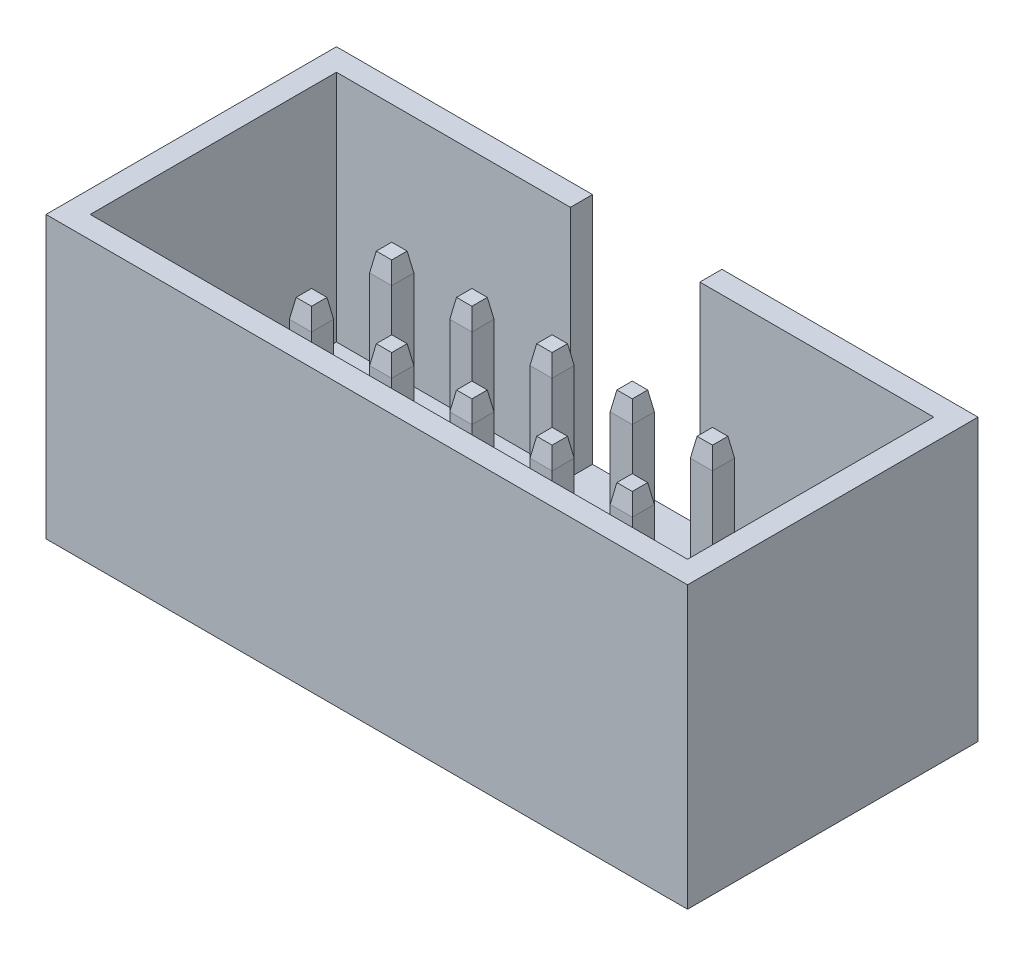
from build123d import *

# Parameters (mm, degrees)
SZKIC1_W                         = 20.32
SZKIC1_H                         = 9.2
DODANIE_WYCI_GNI_CIE1_DEPTH      = 8.9
SZKIC2_W                         = 18.92
SZKIC2_H                         = 7.8
WYTNIJ_WYCI_GNI_CIE1_DEPTH       = 7.4
SZKIC3_W                         = 4.1
SZKIC3_H                         = 0.7
WYTNIJ_WYCI_GNI_CIE2_DEPTH       = 7.4
SZKIC4_W                         = 0.7
SZKIC4_H                         = 0.7
DODANIE_WYCI_GNI_CIE2_DEPTH      = 6
DODANIE_WYCI_GNI_CIE2_DEPTH_BACK = 4
SFAZOWANIE1_SIZE                 = 0.6
SFAZOWANIE1_SIZE2                = 0.105796188
SFAZOWANIE1_PART_2_SIZE          = 0.6
SFAZOWANIE1_PART_2_SIZE2         = 0.105796188
SFAZOWANIE1_PART_3_SIZE          = 0.6
SFAZOWANIE1_PART_3_SIZE2         = 0.105796188
SFAZOWANIE1_PART_4_SIZE          = 0.6
SFAZOWANIE1_PART_4_SIZE2         = 0.105796188
SFAZOWANIE1_PART_5_SIZE          = 0.6
SFAZOWANIE1_PART_5_SIZE2         = 0.105796188
SFAZOWANIE1_PART_6_SIZE          = 0.6
SFAZOWANIE1_PART_6_SIZE2         = 0.105796188
SFAZOWANIE1_PART_7_SIZE          = 0.6
SFAZOWANIE1_PART_7_SIZE2         = 0.105796188
SFAZOWANIE1_PART_8_SIZE          = 0.6
SFAZOWANIE1_PART_8_SIZE2         = 0.105796188
SFAZOWANIE1_PART_9_SIZE          = 0.6
SFAZOWANIE1_PART_9_SIZE2         = 0.105796188
SFAZOWANIE1_PART_10_SIZE         = 0.6
SFAZOWANIE1_PART_10_SIZE2        = 0.105796188
SFAZOWANIE1_PART_11_SIZE         = 0.6
SFAZOWANIE1_PART_11_SIZE2        = 0.105796188
SFAZOWANIE1_PART_12_SIZE         = 0.6
SFAZOWANIE1_PART_12_SIZE2        = 0.105796188
SFAZOWANIE1_PART_13_SIZE         = 0.6
SFAZOWANIE1_PART_13_SIZE2        = 0.105796188
SFAZOWANIE1_PART_14_SIZE         = 0.6
SFAZOWANIE1_PART_14_SIZE2        = 0.105796188
SFAZOWANIE1_PART_15_SIZE         = 0.6
SFAZOWANIE1_PART_15_SIZE2        = 0.105796188
SFAZOWANIE1_PART_16_SIZE         = 0.6
SFAZOWANIE1_PART_16_SIZE2        = 0.105796188
SFAZOWANIE1_PART_17_SIZE         = 0.6
SFAZOWANIE1_PART_17_SIZE2        = 0.105796188
SFAZOWANIE1_PART_18_SIZE         = 0.6
SFAZOWANIE1_PART_18_SIZE2        = 0.105796188
SFAZOWANIE1_PART_19_SIZE         = 0.6
SFAZOWANIE1_PART_19_SIZE2        = 0.105796188
SFAZOWANIE1_PART_20_SIZE         = 0.6
SFAZOWANIE1_PART_20_SIZE2        = 0.105796188
SFAZOWANIE1_PART_21_SIZE         = 0.6
SFAZOWANIE1_PART_21_SIZE2        = 0.105796188
SFAZOWANIE1_PART_22_SIZE         = 0.6
SFAZOWANIE1_PART_22_SIZE2        = 0.105796188
SFAZOWANIE1_PART_23_SIZE         = 0.6
SFAZOWANIE1_PART_23_SIZE2        = 0.105796188
SFAZOWANIE1_PART_24_SIZE         = 0.6
SFAZOWANIE1_PART_24_SIZE2        = 0.105796188
SFAZOWANIE1_PART_25_SIZE         = 0.6
SFAZOWANIE1_PART_25_SIZE2        = 0.105796188
SFAZOWANIE1_PART_26_SIZE         = 0.6
SFAZOWANIE1_PART_26_SIZE2        = 0.105796188
SFAZOWANIE1_PART_27_SIZE         = 0.6
SFAZOWANIE1_PART_27_SIZE2        = 0.105796188
SFAZOWANIE1_PART_28_SIZE         = 0.6
SFAZOWANIE1_PART_28_SIZE2        = 0.105796188
SFAZOWANIE1_PART_29_SIZE         = 0.6
SFAZOWANIE1_PART_29_SIZE2        = 0.105796188
SFAZOWANIE1_PART_30_SIZE         = 0.6
SFAZOWANIE1_PART_30_SIZE2        = 0.105796188
SFAZOWANIE1_PART_31_SIZE         = 0.6
SFAZOWANIE1_PART_31_SIZE2        = 0.105796188
SFAZOWANIE1_PART_32_SIZE         = 0.6
SFAZOWANIE1_PART_32_SIZE2        = 0.105796188
SFAZOWANIE1_PART_33_SIZE         = 0.6
SFAZOWANIE1_PART_33_SIZE2        = 0.105796188
SFAZOWANIE1_PART_34_SIZE         = 0.6
SFAZOWANIE1_PART_34_SIZE2        = 0.105796188
SFAZOWANIE1_PART_35_SIZE         = 0.6
SFAZOWANIE1_PART_35_SIZE2        = 0.105796188
SFAZOWANIE1_PART_36_SIZE         = 0.6
SFAZOWANIE1_PART_36_SIZE2        = 0.105796188
SFAZOWANIE1_PART_37_SIZE         = 0.6
SFAZOWANIE1_PART_37_SIZE2        = 0.105796188
SFAZOWANIE1_PART_38_SIZE         = 0.6
SFAZOWANIE1_PART_38_SIZE2        = 0.105796188
SFAZOWANIE1_PART_39_SIZE         = 0.6
SFAZOWANIE1_PART_39_SIZE2        = 0.105796188
SFAZOWANIE1_PART_40_SIZE         = 0.6
SFAZOWANIE1_PART_40_SIZE2        = 0.105796188
SFAZOWANIE2_SIZE                 = 0.6
SFAZOWANIE2_SIZE2                = 0.105796188
SFAZOWANIE2_PART_2_SIZE          = 0.6
SFAZOWANIE2_PART_2_SIZE2         = 0.105796188
SFAZOWANIE2_PART_3_SIZE          = 0.6
SFAZOWANIE2_PART_3_SIZE2         = 0.105796188
SFAZOWANIE2_PART_4_SIZE          = 0.6
SFAZOWANIE2_PART_4_SIZE2         = 0.105796188
SFAZOWANIE2_PART_5_SIZE          = 0.6
SFAZOWANIE2_PART_5_SIZE2         = 0.105796188
SFAZOWANIE2_PART_6_SIZE          = 0.6
SFAZOWANIE2_PART_6_SIZE2         = 0.105796188
SFAZOWANIE2_PART_7_SIZE          = 0.6
SFAZOWANIE2_PART_7_SIZE2         = 0.105796188
SFAZOWANIE2_PART_8_SIZE          = 0.6
SFAZOWANIE2_PART_8_SIZE2         = 0.105796188
SFAZOWANIE2_PART_9_SIZE          = 0.6
SFAZOWANIE2_PART_9_SIZE2         = 0.105796188
SFAZOWANIE2_PART_10_SIZE         = 0.6
SFAZOWANIE2_PART_10_SIZE2        = 0.105796188
SFAZOWANIE2_PART_11_SIZE         = 0.6
SFAZOWANIE2_PART_11_SIZE2        = 0.105796188
SFAZOWANIE2_PART_12_SIZE         = 0.6
SFAZOWANIE2_PART_12_SIZE2        = 0.105796188
SFAZOWANIE2_PART_13_SIZE         = 0.6
SFAZOWANIE2_PART_13_SIZE2        = 0.105796188
SFAZOWANIE2_PART_14_SIZE         = 0.6
SFAZOWANIE2_PART_14_SIZE2        = 0.105796188
SFAZOWANIE2_PART_15_SIZE         = 0.6
SFAZOWANIE2_PART_15_SIZE2        = 0.105796188
SFAZOWANIE2_PART_16_SIZE         = 0.6
SFAZOWANIE2_PART_16_SIZE2        = 0.105796188
SFAZOWANIE2_PART_17_SIZE         = 0.6
SFAZOWANIE2_PART_17_SIZE2        = 0.105796188
SFAZOWANIE2_PART_18_SIZE         = 0.6
SFAZOWANIE2_PART_18_SIZE2        = 0.105796188
SFAZOWANIE2_PART_19_SIZE         = 0.6
SFAZOWANIE2_PART_19_SIZE2        = 0.105796188
SFAZOWANIE2_PART_20_SIZE         = 0.6
SFAZOWANIE2_PART_20_SIZE2        = 0.105796188
SFAZOWANIE2_PART_21_SIZE         = 0.6
SFAZOWANIE2_PART_21_SIZE2        = 0.105796188
SFAZOWANIE2_PART_22_SIZE         = 0.6
SFAZOWANIE2_PART_22_SIZE2        = 0.105796188
SFAZOWANIE2_PART_23_SIZE         = 0.6
SFAZOWANIE2_PART_23_SIZE2        = 0.105796188
SFAZOWANIE2_PART_24_SIZE         = 0.6
SFAZOWANIE2_PART_24_SIZE2        = 0.105796188
SFAZOWANIE2_PART_25_SIZE         = 0.6
SFAZOWANIE2_PART_25_SIZE2        = 0.105796188
SFAZOWANIE2_PART_26_SIZE         = 0.6
SFAZOWANIE2_PART_26_SIZE2        = 0.105796188
SFAZOWANIE2_PART_27_SIZE         = 0.6
SFAZOWANIE2_PART_27_SIZE2        = 0.105796188
SFAZOWANIE2_PART_28_SIZE         = 0.6
SFAZOWANIE2_PART_28_SIZE2        = 0.105796188
SFAZOWANIE2_PART_29_SIZE         = 0.6
SFAZOWANIE2_PART_29_SIZE2        = 0.105796188
SFAZOWANIE2_PART_30_SIZE         = 0.6
SFAZOWANIE2_PART_30_SIZE2        = 0.105796188
SFAZOWANIE2_PART_31_SIZE         = 0.6
SFAZOWANIE2_PART_31_SIZE2        = 0.105796188
SFAZOWANIE2_PART_32_SIZE         = 0.6
SFAZOWANIE2_PART_32_SIZE2        = 0.105796188
SFAZOWANIE2_PART_33_SIZE         = 0.6
SFAZOWANIE2_PART_33_SIZE2        = 0.105796188
SFAZOWANIE2_PART_34_SIZE         = 0.6
SFAZOWANIE2_PART_34_SIZE2        = 0.105796188
SFAZOWANIE2_PART_35_SIZE         = 0.6
SFAZOWANIE2_PART_35_SIZE2        = 0.105796188
SFAZOWANIE2_PART_36_SIZE         = 0.6
SFAZOWANIE2_PART_36_SIZE2        = 0.105796188
SFAZOWANIE2_PART_37_SIZE         = 0.6
SFAZOWANIE2_PART_37_SIZE2        = 0.105796188
SFAZOWANIE2_PART_38_SIZE         = 0.6
SFAZOWANIE2_PART_38_SIZE2        = 0.105796188
SFAZOWANIE2_PART_39_SIZE         = 0.6
SFAZOWANIE2_PART_39_SIZE2        = 0.105796188
SFAZOWANIE2_PART_40_SIZE         = 0.6
SFAZOWANIE2_PART_40_SIZE2        = 0.105796188


with BuildPart() as part:
    # Szkic1 → Dodanie-wyciągnięcie1 (new body)
    with BuildSketch(Plane(origin=(0, 0, 0), x_dir=(1, 0, 0), z_dir=(0, 1, 0))):
        with Locations((10.16, 4.6)):
            Rectangle(SZKIC1_W, SZKIC1_H)
    extrude(amount=DODANIE_WYCI_GNI_CIE1_DEPTH)

    # Szkic2 → Wytnij-wyciągnięcie1 (cut)
    with BuildSketch(Plane(origin=(0, 8.9, 0), x_dir=(1, 0, 0), z_dir=(0, 1, 0))):
        with Locations((10.16, 4.6)):
            Rectangle(SZKIC2_W, SZKIC2_H)
    extrude(amount=-WYTNIJ_WYCI_GNI_CIE1_DEPTH, mode=Mode.SUBTRACT)

    # Szkic3 → Wytnij-wyciągnięcie2 (cut)
    with BuildSketch(Plane(origin=(0, 8.9, 0), x_dir=(1, 0, 0), z_dir=(0, 1, 0))):
        with Locations((10.16, 8.85)):
            Rectangle(SZKIC3_W, SZKIC3_H)
    extrude(amount=-WYTNIJ_WYCI_GNI_CIE2_DEPTH, mode=Mode.SUBTRACT)

    # Szkic4 → Dodanie-wyciągnięcie2 (add, two sides)
    with BuildSketch(Plane(origin=(0, 1.5, 0), x_dir=(1, 0, 0), z_dir=(0, 1, 0))) as dodanie_wyci_gni_cie2_sk:
        with Locations((5.08, 5.87)):
            Rectangle(SZKIC4_W, SZKIC4_H)
        with Locations((7.62, 5.87)):
            Rectangle(SZKIC4_W, SZKIC4_H)
        with Locations((10.16, 5.87)):
            Rectangle(SZKIC4_W, SZKIC4_H)
        with Locations((12.7, 5.87)):
            Rectangle(SZKIC4_W, SZKIC4_H)
        with Locations((15.24, 5.87)):
            Rectangle(SZKIC4_W, SZKIC4_H)
        with Locations((7.62, 3.33)):
            Rectangle(SZKIC4_W, SZKIC4_H)
        with Locations((10.16, 3.33)):
            Rectangle(SZKIC4_W, SZKIC4_H)
        with Locations((12.7, 3.33)):
            Rectangle(SZKIC4_W, SZKIC4_H)
        with Locations((15.24, 3.33)):
            Rectangle(SZKIC4_W, SZKIC4_H)
        with Locations((5.08, 3.33)):
            Rectangle(SZKIC4_W, SZKIC4_H)
    extrude(amount=DODANIE_WYCI_GNI_CIE2_DEPTH)
    extrude(dodanie_wyci_gni_cie2_sk.sketch, amount=-DODANIE_WYCI_GNI_CIE2_DEPTH_BACK)

    # Sfazowanie1
    sfazowanie1_edges = [part.edges().sort_by_distance(p)[0] for p in [
        (12.7, 7.5, -5.52),
    ]]
    sfazowanie1_side = [part.faces().sort_by_distance(p)[0] for p in [
        (12.7, 4.5, -5.52),
    ]]
    chamfer(sfazowanie1_edges, length=SFAZOWANIE1_SIZE, length2=SFAZOWANIE1_SIZE2, reference=sfazowanie1_side[0])

    # Sfazowanie1 part 2
    sfazowanie1_part_2_edges = [part.edges().sort_by_distance(p)[0] for p in [
        (13.05, 7.5, -5.87),
    ]]
    sfazowanie1_part_2_side = [part.faces().sort_by_distance(p)[0] for p in [
        (13.05, 4.5, -5.87),
    ]]
    chamfer(sfazowanie1_part_2_edges, length=SFAZOWANIE1_PART_2_SIZE, length2=SFAZOWANIE1_PART_2_SIZE2, reference=sfazowanie1_part_2_side[0])

    # Sfazowanie1 part 3
    sfazowanie1_part_3_edges = [part.edges().sort_by_distance(p)[0] for p in [
        (12.7, 7.5, -6.22),
    ]]
    sfazowanie1_part_3_side = [part.faces().sort_by_distance(p)[0] for p in [
        (12.7, 4.5, -6.22),
    ]]
    chamfer(sfazowanie1_part_3_edges, length=SFAZOWANIE1_PART_3_SIZE, length2=SFAZOWANIE1_PART_3_SIZE2, reference=sfazowanie1_part_3_side[0])

    # Sfazowanie1 part 4
    sfazowanie1_part_4_edges = [part.edges().sort_by_distance(p)[0] for p in [
        (12.35, 7.5, -5.87),
    ]]
    sfazowanie1_part_4_side = [part.faces().sort_by_distance(p)[0] for p in [
        (12.35, 4.5, -5.87),
    ]]
    chamfer(sfazowanie1_part_4_edges, length=SFAZOWANIE1_PART_4_SIZE, length2=SFAZOWANIE1_PART_4_SIZE2, reference=sfazowanie1_part_4_side[0])

    # Sfazowanie1 part 5
    sfazowanie1_part_5_edges = [part.edges().sort_by_distance(p)[0] for p in [
        (15.24, 7.5, -5.52),
    ]]
    sfazowanie1_part_5_side = [part.faces().sort_by_distance(p)[0] for p in [
        (15.24, 4.5, -5.52),
    ]]
    chamfer(sfazowanie1_part_5_edges, length=SFAZOWANIE1_PART_5_SIZE, length2=SFAZOWANIE1_PART_5_SIZE2, reference=sfazowanie1_part_5_side[0])

    # Sfazowanie1 part 6
    sfazowanie1_part_6_edges = [part.edges().sort_by_distance(p)[0] for p in [
        (15.59, 7.5, -5.87),
    ]]
    sfazowanie1_part_6_side = [part.faces().sort_by_distance(p)[0] for p in [
        (15.59, 4.5, -5.87),
    ]]
    chamfer(sfazowanie1_part_6_edges, length=SFAZOWANIE1_PART_6_SIZE, length2=SFAZOWANIE1_PART_6_SIZE2, reference=sfazowanie1_part_6_side[0])

    # Sfazowanie1 part 7
    sfazowanie1_part_7_edges = [part.edges().sort_by_distance(p)[0] for p in [
        (15.24, 7.5, -6.22),
    ]]
    sfazowanie1_part_7_side = [part.faces().sort_by_distance(p)[0] for p in [
        (15.24, 4.5, -6.22),
    ]]
    chamfer(sfazowanie1_part_7_edges, length=SFAZOWANIE1_PART_7_SIZE, length2=SFAZOWANIE1_PART_7_SIZE2, reference=sfazowanie1_part_7_side[0])

    # Sfazowanie1 part 8
    sfazowanie1_part_8_edges = [part.edges().sort_by_distance(p)[0] for p in [
        (14.89, 7.5, -5.87),
    ]]
    sfazowanie1_part_8_side = [part.faces().sort_by_distance(p)[0] for p in [
        (14.89, 4.5, -5.87),
    ]]
    chamfer(sfazowanie1_part_8_edges, length=SFAZOWANIE1_PART_8_SIZE, length2=SFAZOWANIE1_PART_8_SIZE2, reference=sfazowanie1_part_8_side[0])

    # Sfazowanie1 part 9
    sfazowanie1_part_9_edges = [part.edges().sort_by_distance(p)[0] for p in [
        (7.62, 7.5, -2.98),
    ]]
    sfazowanie1_part_9_side = [part.faces().sort_by_distance(p)[0] for p in [
        (7.62, 4.5, -2.98),
    ]]
    chamfer(sfazowanie1_part_9_edges, length=SFAZOWANIE1_PART_9_SIZE, length2=SFAZOWANIE1_PART_9_SIZE2, reference=sfazowanie1_part_9_side[0])

    # Sfazowanie1 part 10
    sfazowanie1_part_10_edges = [part.edges().sort_by_distance(p)[0] for p in [
        (7.97, 7.5, -3.33),
    ]]
    sfazowanie1_part_10_side = [part.faces().sort_by_distance(p)[0] for p in [
        (7.97, 4.5, -3.33),
    ]]
    chamfer(sfazowanie1_part_10_edges, length=SFAZOWANIE1_PART_10_SIZE, length2=SFAZOWANIE1_PART_10_SIZE2, reference=sfazowanie1_part_10_side[0])

    # Sfazowanie1 part 11
    sfazowanie1_part_11_edges = [part.edges().sort_by_distance(p)[0] for p in [
        (7.62, 7.5, -3.68),
    ]]
    sfazowanie1_part_11_side = [part.faces().sort_by_distance(p)[0] for p in [
        (7.62, 4.5, -3.68),
    ]]
    chamfer(sfazowanie1_part_11_edges, length=SFAZOWANIE1_PART_11_SIZE, length2=SFAZOWANIE1_PART_11_SIZE2, reference=sfazowanie1_part_11_side[0])

    # Sfazowanie1 part 12
    sfazowanie1_part_12_edges = [part.edges().sort_by_distance(p)[0] for p in [
        (7.27, 7.5, -3.33),
    ]]
    sfazowanie1_part_12_side = [part.faces().sort_by_distance(p)[0] for p in [
        (7.27, 4.5, -3.33),
    ]]
    chamfer(sfazowanie1_part_12_edges, length=SFAZOWANIE1_PART_12_SIZE, length2=SFAZOWANIE1_PART_12_SIZE2, reference=sfazowanie1_part_12_side[0])

    # Sfazowanie1 part 13
    sfazowanie1_part_13_edges = [part.edges().sort_by_distance(p)[0] for p in [
        (10.16, 7.5, -2.98),
    ]]
    sfazowanie1_part_13_side = [part.faces().sort_by_distance(p)[0] for p in [
        (10.16, 4.5, -2.98),
    ]]
    chamfer(sfazowanie1_part_13_edges, length=SFAZOWANIE1_PART_13_SIZE, length2=SFAZOWANIE1_PART_13_SIZE2, reference=sfazowanie1_part_13_side[0])

    # Sfazowanie1 part 14
    sfazowanie1_part_14_edges = [part.edges().sort_by_distance(p)[0] for p in [
        (10.51, 7.5, -3.33),
    ]]
    sfazowanie1_part_14_side = [part.faces().sort_by_distance(p)[0] for p in [
        (10.51, 4.5, -3.33),
    ]]
    chamfer(sfazowanie1_part_14_edges, length=SFAZOWANIE1_PART_14_SIZE, length2=SFAZOWANIE1_PART_14_SIZE2, reference=sfazowanie1_part_14_side[0])

    # Sfazowanie1 part 15
    sfazowanie1_part_15_edges = [part.edges().sort_by_distance(p)[0] for p in [
        (10.16, 7.5, -3.68),
    ]]
    sfazowanie1_part_15_side = [part.faces().sort_by_distance(p)[0] for p in [
        (10.16, 4.5, -3.68),
    ]]
    chamfer(sfazowanie1_part_15_edges, length=SFAZOWANIE1_PART_15_SIZE, length2=SFAZOWANIE1_PART_15_SIZE2, reference=sfazowanie1_part_15_side[0])

    # Sfazowanie1 part 16
    sfazowanie1_part_16_edges = [part.edges().sort_by_distance(p)[0] for p in [
        (9.81, 7.5, -3.33),
    ]]
    sfazowanie1_part_16_side = [part.faces().sort_by_distance(p)[0] for p in [
        (9.81, 4.5, -3.33),
    ]]
    chamfer(sfazowanie1_part_16_edges, length=SFAZOWANIE1_PART_16_SIZE, length2=SFAZOWANIE1_PART_16_SIZE2, reference=sfazowanie1_part_16_side[0])

    # Sfazowanie1 part 17
    sfazowanie1_part_17_edges = [part.edges().sort_by_distance(p)[0] for p in [
        (12.7, 7.5, -2.98),
    ]]
    sfazowanie1_part_17_side = [part.faces().sort_by_distance(p)[0] for p in [
        (12.7, 4.5, -2.98),
    ]]
    chamfer(sfazowanie1_part_17_edges, length=SFAZOWANIE1_PART_17_SIZE, length2=SFAZOWANIE1_PART_17_SIZE2, reference=sfazowanie1_part_17_side[0])

    # Sfazowanie1 part 18
    sfazowanie1_part_18_edges = [part.edges().sort_by_distance(p)[0] for p in [
        (13.05, 7.5, -3.33),
    ]]
    sfazowanie1_part_18_side = [part.faces().sort_by_distance(p)[0] for p in [
        (13.05, 4.5, -3.33),
    ]]
    chamfer(sfazowanie1_part_18_edges, length=SFAZOWANIE1_PART_18_SIZE, length2=SFAZOWANIE1_PART_18_SIZE2, reference=sfazowanie1_part_18_side[0])

    # Sfazowanie1 part 19
    sfazowanie1_part_19_edges = [part.edges().sort_by_distance(p)[0] for p in [
        (12.7, 7.5, -3.68),
    ]]
    sfazowanie1_part_19_side = [part.faces().sort_by_distance(p)[0] for p in [
        (12.7, 4.5, -3.68),
    ]]
    chamfer(sfazowanie1_part_19_edges, length=SFAZOWANIE1_PART_19_SIZE, length2=SFAZOWANIE1_PART_19_SIZE2, reference=sfazowanie1_part_19_side[0])

    # Sfazowanie1 part 20
    sfazowanie1_part_20_edges = [part.edges().sort_by_distance(p)[0] for p in [
        (12.35, 7.5, -3.33),
    ]]
    sfazowanie1_part_20_side = [part.faces().sort_by_distance(p)[0] for p in [
        (12.35, 4.5, -3.33),
    ]]
    chamfer(sfazowanie1_part_20_edges, length=SFAZOWANIE1_PART_20_SIZE, length2=SFAZOWANIE1_PART_20_SIZE2, reference=sfazowanie1_part_20_side[0])

    # Sfazowanie1 part 21
    sfazowanie1_part_21_edges = [part.edges().sort_by_distance(p)[0] for p in [
        (15.24, 7.5, -2.98),
    ]]
    sfazowanie1_part_21_side = [part.faces().sort_by_distance(p)[0] for p in [
        (15.24, 4.5, -2.98),
    ]]
    chamfer(sfazowanie1_part_21_edges, length=SFAZOWANIE1_PART_21_SIZE, length2=SFAZOWANIE1_PART_21_SIZE2, reference=sfazowanie1_part_21_side[0])

    # Sfazowanie1 part 22
    sfazowanie1_part_22_edges = [part.edges().sort_by_distance(p)[0] for p in [
        (15.59, 7.5, -3.33),
    ]]
    sfazowanie1_part_22_side = [part.faces().sort_by_distance(p)[0] for p in [
        (15.59, 4.5, -3.33),
    ]]
    chamfer(sfazowanie1_part_22_edges, length=SFAZOWANIE1_PART_22_SIZE, length2=SFAZOWANIE1_PART_22_SIZE2, reference=sfazowanie1_part_22_side[0])

    # Sfazowanie1 part 23
    sfazowanie1_part_23_edges = [part.edges().sort_by_distance(p)[0] for p in [
        (15.24, 7.5, -3.68),
    ]]
    sfazowanie1_part_23_side = [part.faces().sort_by_distance(p)[0] for p in [
        (15.24, 4.5, -3.68),
    ]]
    chamfer(sfazowanie1_part_23_edges, length=SFAZOWANIE1_PART_23_SIZE, length2=SFAZOWANIE1_PART_23_SIZE2, reference=sfazowanie1_part_23_side[0])

    # Sfazowanie1 part 24
    sfazowanie1_part_24_edges = [part.edges().sort_by_distance(p)[0] for p in [
        (14.89, 7.5, -3.33),
    ]]
    sfazowanie1_part_24_side = [part.faces().sort_by_distance(p)[0] for p in [
        (14.89, 4.5, -3.33),
    ]]
    chamfer(sfazowanie1_part_24_edges, length=SFAZOWANIE1_PART_24_SIZE, length2=SFAZOWANIE1_PART_24_SIZE2, reference=sfazowanie1_part_24_side[0])

    # Sfazowanie1 part 25
    sfazowanie1_part_25_edges = [part.edges().sort_by_distance(p)[0] for p in [
        (5.08, 7.5, -2.98),
    ]]
    sfazowanie1_part_25_side = [part.faces().sort_by_distance(p)[0] for p in [
        (5.08, 4.5, -2.98),
    ]]
    chamfer(sfazowanie1_part_25_edges, length=SFAZOWANIE1_PART_25_SIZE, length2=SFAZOWANIE1_PART_25_SIZE2, reference=sfazowanie1_part_25_side[0])

    # Sfazowanie1 part 26
    sfazowanie1_part_26_edges = [part.edges().sort_by_distance(p)[0] for p in [
        (5.43, 7.5, -3.33),
    ]]
    sfazowanie1_part_26_side = [part.faces().sort_by_distance(p)[0] for p in [
        (5.43, 4.5, -3.33),
    ]]
    chamfer(sfazowanie1_part_26_edges, length=SFAZOWANIE1_PART_26_SIZE, length2=SFAZOWANIE1_PART_26_SIZE2, reference=sfazowanie1_part_26_side[0])

    # Sfazowanie1 part 27
    sfazowanie1_part_27_edges = [part.edges().sort_by_distance(p)[0] for p in [
        (5.08, 7.5, -3.68),
    ]]
    sfazowanie1_part_27_side = [part.faces().sort_by_distance(p)[0] for p in [
        (5.08, 4.5, -3.68),
    ]]
    chamfer(sfazowanie1_part_27_edges, length=SFAZOWANIE1_PART_27_SIZE, length2=SFAZOWANIE1_PART_27_SIZE2, reference=sfazowanie1_part_27_side[0])

    # Sfazowanie1 part 28
    sfazowanie1_part_28_edges = [part.edges().sort_by_distance(p)[0] for p in [
        (4.73, 7.5, -3.33),
    ]]
    sfazowanie1_part_28_side = [part.faces().sort_by_distance(p)[0] for p in [
        (4.73, 4.5, -3.33),
    ]]
    chamfer(sfazowanie1_part_28_edges, length=SFAZOWANIE1_PART_28_SIZE, length2=SFAZOWANIE1_PART_28_SIZE2, reference=sfazowanie1_part_28_side[0])

    # Sfazowanie1 part 29
    sfazowanie1_part_29_edges = [part.edges().sort_by_distance(p)[0] for p in [
        (5.43, 7.5, -5.87),
    ]]
    sfazowanie1_part_29_side = [part.faces().sort_by_distance(p)[0] for p in [
        (5.43, 4.5, -5.87),
    ]]
    chamfer(sfazowanie1_part_29_edges, length=SFAZOWANIE1_PART_29_SIZE, length2=SFAZOWANIE1_PART_29_SIZE2, reference=sfazowanie1_part_29_side[0])

    # Sfazowanie1 part 30
    sfazowanie1_part_30_edges = [part.edges().sort_by_distance(p)[0] for p in [
        (5.08, 7.5, -6.22),
    ]]
    sfazowanie1_part_30_side = [part.faces().sort_by_distance(p)[0] for p in [
        (5.08, 4.5, -6.22),
    ]]
    chamfer(sfazowanie1_part_30_edges, length=SFAZOWANIE1_PART_30_SIZE, length2=SFAZOWANIE1_PART_30_SIZE2, reference=sfazowanie1_part_30_side[0])

    # Sfazowanie1 part 31
    sfazowanie1_part_31_edges = [part.edges().sort_by_distance(p)[0] for p in [
        (4.73, 7.5, -5.87),
    ]]
    sfazowanie1_part_31_side = [part.faces().sort_by_distance(p)[0] for p in [
        (4.73, 4.5, -5.87),
    ]]
    chamfer(sfazowanie1_part_31_edges, length=SFAZOWANIE1_PART_31_SIZE, length2=SFAZOWANIE1_PART_31_SIZE2, reference=sfazowanie1_part_31_side[0])

    # Sfazowanie1 part 32
    sfazowanie1_part_32_edges = [part.edges().sort_by_distance(p)[0] for p in [
        (5.08, 7.5, -5.52),
    ]]
    sfazowanie1_part_32_side = [part.faces().sort_by_distance(p)[0] for p in [
        (5.08, 4.5, -5.52),
    ]]
    chamfer(sfazowanie1_part_32_edges, length=SFAZOWANIE1_PART_32_SIZE, length2=SFAZOWANIE1_PART_32_SIZE2, reference=sfazowanie1_part_32_side[0])

    # Sfazowanie1 part 33
    sfazowanie1_part_33_edges = [part.edges().sort_by_distance(p)[0] for p in [
        (7.62, 7.5, -5.52),
    ]]
    sfazowanie1_part_33_side = [part.faces().sort_by_distance(p)[0] for p in [
        (7.62, 4.5, -5.52),
    ]]
    chamfer(sfazowanie1_part_33_edges, length=SFAZOWANIE1_PART_33_SIZE, length2=SFAZOWANIE1_PART_33_SIZE2, reference=sfazowanie1_part_33_side[0])

    # Sfazowanie1 part 34
    sfazowanie1_part_34_edges = [part.edges().sort_by_distance(p)[0] for p in [
        (7.97, 7.5, -5.87),
    ]]
    sfazowanie1_part_34_side = [part.faces().sort_by_distance(p)[0] for p in [
        (7.97, 4.5, -5.87),
    ]]
    chamfer(sfazowanie1_part_34_edges, length=SFAZOWANIE1_PART_34_SIZE, length2=SFAZOWANIE1_PART_34_SIZE2, reference=sfazowanie1_part_34_side[0])

    # Sfazowanie1 part 35
    sfazowanie1_part_35_edges = [part.edges().sort_by_distance(p)[0] for p in [
        (7.62, 7.5, -6.22),
    ]]
    sfazowanie1_part_35_side = [part.faces().sort_by_distance(p)[0] for p in [
        (7.62, 4.5, -6.22),
    ]]
    chamfer(sfazowanie1_part_35_edges, length=SFAZOWANIE1_PART_35_SIZE, length2=SFAZOWANIE1_PART_35_SIZE2, reference=sfazowanie1_part_35_side[0])

    # Sfazowanie1 part 36
    sfazowanie1_part_36_edges = [part.edges().sort_by_distance(p)[0] for p in [
        (7.27, 7.5, -5.87),
    ]]
    sfazowanie1_part_36_side = [part.faces().sort_by_distance(p)[0] for p in [
        (7.27, 4.5, -5.87),
    ]]
    chamfer(sfazowanie1_part_36_edges, length=SFAZOWANIE1_PART_36_SIZE, length2=SFAZOWANIE1_PART_36_SIZE2, reference=sfazowanie1_part_36_side[0])

    # Sfazowanie1 part 37
    sfazowanie1_part_37_edges = [part.edges().sort_by_distance(p)[0] for p in [
        (10.16, 7.5, -5.52),
    ]]
    sfazowanie1_part_37_side = [part.faces().sort_by_distance(p)[0] for p in [
        (10.16, 4.5, -5.52),
    ]]
    chamfer(sfazowanie1_part_37_edges, length=SFAZOWANIE1_PART_37_SIZE, length2=SFAZOWANIE1_PART_37_SIZE2, reference=sfazowanie1_part_37_side[0])

    # Sfazowanie1 part 38
    sfazowanie1_part_38_edges = [part.edges().sort_by_distance(p)[0] for p in [
        (10.51, 7.5, -5.87),
    ]]
    sfazowanie1_part_38_side = [part.faces().sort_by_distance(p)[0] for p in [
        (10.51, 4.5, -5.87),
    ]]
    chamfer(sfazowanie1_part_38_edges, length=SFAZOWANIE1_PART_38_SIZE, length2=SFAZOWANIE1_PART_38_SIZE2, reference=sfazowanie1_part_38_side[0])

    # Sfazowanie1 part 39
    sfazowanie1_part_39_edges = [part.edges().sort_by_distance(p)[0] for p in [
        (10.16, 7.5, -6.22),
    ]]
    sfazowanie1_part_39_side = [part.faces().sort_by_distance(p)[0] for p in [
        (10.16, 4.5, -6.22),
    ]]
    chamfer(sfazowanie1_part_39_edges, length=SFAZOWANIE1_PART_39_SIZE, length2=SFAZOWANIE1_PART_39_SIZE2, reference=sfazowanie1_part_39_side[0])

    # Sfazowanie1 part 40
    sfazowanie1_part_40_edges = [part.edges().sort_by_distance(p)[0] for p in [
        (9.81, 7.5, -5.87),
    ]]
    sfazowanie1_part_40_side = [part.faces().sort_by_distance(p)[0] for p in [
        (9.81, 4.5, -5.87),
    ]]
    chamfer(sfazowanie1_part_40_edges, length=SFAZOWANIE1_PART_40_SIZE, length2=SFAZOWANIE1_PART_40_SIZE2, reference=sfazowanie1_part_40_side[0])

    # Sfazowanie2
    sfazowanie2_edges = [part.edges().sort_by_distance(p)[0] for p in [
        (12.7, -2.5, -5.52),
    ]]
    sfazowanie2_side = [part.faces().sort_by_distance(p)[0] for p in [
        (12.7, -1.25, -5.52),
    ]]
    chamfer(sfazowanie2_edges, length=SFAZOWANIE2_SIZE, length2=SFAZOWANIE2_SIZE2, reference=sfazowanie2_side[0])

    # Sfazowanie2 part 2
    sfazowanie2_part_2_edges = [part.edges().sort_by_distance(p)[0] for p in [
        (12.35, -2.5, -5.87),
    ]]
    sfazowanie2_part_2_side = [part.faces().sort_by_distance(p)[0] for p in [
        (12.35, -1.25, -5.87),
    ]]
    chamfer(sfazowanie2_part_2_edges, length=SFAZOWANIE2_PART_2_SIZE, length2=SFAZOWANIE2_PART_2_SIZE2, reference=sfazowanie2_part_2_side[0])

    # Sfazowanie2 part 3
    sfazowanie2_part_3_edges = [part.edges().sort_by_distance(p)[0] for p in [
        (12.7, -2.5, -6.22),
    ]]
    sfazowanie2_part_3_side = [part.faces().sort_by_distance(p)[0] for p in [
        (12.7, -1.25, -6.22),
    ]]
    chamfer(sfazowanie2_part_3_edges, length=SFAZOWANIE2_PART_3_SIZE, length2=SFAZOWANIE2_PART_3_SIZE2, reference=sfazowanie2_part_3_side[0])

    # Sfazowanie2 part 4
    sfazowanie2_part_4_edges = [part.edges().sort_by_distance(p)[0] for p in [
        (13.05, -2.5, -5.87),
    ]]
    sfazowanie2_part_4_side = [part.faces().sort_by_distance(p)[0] for p in [
        (13.05, -1.25, -5.87),
    ]]
    chamfer(sfazowanie2_part_4_edges, length=SFAZOWANIE2_PART_4_SIZE, length2=SFAZOWANIE2_PART_4_SIZE2, reference=sfazowanie2_part_4_side[0])

    # Sfazowanie2 part 5
    sfazowanie2_part_5_edges = [part.edges().sort_by_distance(p)[0] for p in [
        (15.24, -2.5, -5.52),
    ]]
    sfazowanie2_part_5_side = [part.faces().sort_by_distance(p)[0] for p in [
        (15.24, -1.25, -5.52),
    ]]
    chamfer(sfazowanie2_part_5_edges, length=SFAZOWANIE2_PART_5_SIZE, length2=SFAZOWANIE2_PART_5_SIZE2, reference=sfazowanie2_part_5_side[0])

    # Sfazowanie2 part 6
    sfazowanie2_part_6_edges = [part.edges().sort_by_distance(p)[0] for p in [
        (14.89, -2.5, -5.87),
    ]]
    sfazowanie2_part_6_side = [part.faces().sort_by_distance(p)[0] for p in [
        (14.89, -1.25, -5.87),
    ]]
    chamfer(sfazowanie2_part_6_edges, length=SFAZOWANIE2_PART_6_SIZE, length2=SFAZOWANIE2_PART_6_SIZE2, reference=sfazowanie2_part_6_side[0])

    # Sfazowanie2 part 7
    sfazowanie2_part_7_edges = [part.edges().sort_by_distance(p)[0] for p in [
        (15.24, -2.5, -6.22),
    ]]
    sfazowanie2_part_7_side = [part.faces().sort_by_distance(p)[0] for p in [
        (15.24, -1.25, -6.22),
    ]]
    chamfer(sfazowanie2_part_7_edges, length=SFAZOWANIE2_PART_7_SIZE, length2=SFAZOWANIE2_PART_7_SIZE2, reference=sfazowanie2_part_7_side[0])

    # Sfazowanie2 part 8
    sfazowanie2_part_8_edges = [part.edges().sort_by_distance(p)[0] for p in [
        (15.59, -2.5, -5.87),
    ]]
    sfazowanie2_part_8_side = [part.faces().sort_by_distance(p)[0] for p in [
        (15.59, -1.25, -5.87),
    ]]
    chamfer(sfazowanie2_part_8_edges, length=SFAZOWANIE2_PART_8_SIZE, length2=SFAZOWANIE2_PART_8_SIZE2, reference=sfazowanie2_part_8_side[0])

    # Sfazowanie2 part 9
    sfazowanie2_part_9_edges = [part.edges().sort_by_distance(p)[0] for p in [
        (7.62, -2.5, -2.98),
    ]]
    sfazowanie2_part_9_side = [part.faces().sort_by_distance(p)[0] for p in [
        (7.62, -1.25, -2.98),
    ]]
    chamfer(sfazowanie2_part_9_edges, length=SFAZOWANIE2_PART_9_SIZE, length2=SFAZOWANIE2_PART_9_SIZE2, reference=sfazowanie2_part_9_side[0])

    # Sfazowanie2 part 10
    sfazowanie2_part_10_edges = [part.edges().sort_by_distance(p)[0] for p in [
        (7.27, -2.5, -3.33),
    ]]
    sfazowanie2_part_10_side = [part.faces().sort_by_distance(p)[0] for p in [
        (7.27, -1.25, -3.33),
    ]]
    chamfer(sfazowanie2_part_10_edges, length=SFAZOWANIE2_PART_10_SIZE, length2=SFAZOWANIE2_PART_10_SIZE2, reference=sfazowanie2_part_10_side[0])

    # Sfazowanie2 part 11
    sfazowanie2_part_11_edges = [part.edges().sort_by_distance(p)[0] for p in [
        (7.62, -2.5, -3.68),
    ]]
    sfazowanie2_part_11_side = [part.faces().sort_by_distance(p)[0] for p in [
        (7.62, -1.25, -3.68),
    ]]
    chamfer(sfazowanie2_part_11_edges, length=SFAZOWANIE2_PART_11_SIZE, length2=SFAZOWANIE2_PART_11_SIZE2, reference=sfazowanie2_part_11_side[0])

    # Sfazowanie2 part 12
    sfazowanie2_part_12_edges = [part.edges().sort_by_distance(p)[0] for p in [
        (7.97, -2.5, -3.33),
    ]]
    sfazowanie2_part_12_side = [part.faces().sort_by_distance(p)[0] for p in [
        (7.97, -1.25, -3.33),
    ]]
    chamfer(sfazowanie2_part_12_edges, length=SFAZOWANIE2_PART_12_SIZE, length2=SFAZOWANIE2_PART_12_SIZE2, reference=sfazowanie2_part_12_side[0])

    # Sfazowanie2 part 13
    sfazowanie2_part_13_edges = [part.edges().sort_by_distance(p)[0] for p in [
        (10.16, -2.5, -2.98),
    ]]
    sfazowanie2_part_13_side = [part.faces().sort_by_distance(p)[0] for p in [
        (10.16, -1.25, -2.98),
    ]]
    chamfer(sfazowanie2_part_13_edges, length=SFAZOWANIE2_PART_13_SIZE, length2=SFAZOWANIE2_PART_13_SIZE2, reference=sfazowanie2_part_13_side[0])

    # Sfazowanie2 part 14
    sfazowanie2_part_14_edges = [part.edges().sort_by_distance(p)[0] for p in [
        (9.81, -2.5, -3.33),
    ]]
    sfazowanie2_part_14_side = [part.faces().sort_by_distance(p)[0] for p in [
        (9.81, -1.25, -3.33),
    ]]
    chamfer(sfazowanie2_part_14_edges, length=SFAZOWANIE2_PART_14_SIZE, length2=SFAZOWANIE2_PART_14_SIZE2, reference=sfazowanie2_part_14_side[0])

    # Sfazowanie2 part 15
    sfazowanie2_part_15_edges = [part.edges().sort_by_distance(p)[0] for p in [
        (10.16, -2.5, -3.68),
    ]]
    sfazowanie2_part_15_side = [part.faces().sort_by_distance(p)[0] for p in [
        (10.16, -1.25, -3.68),
    ]]
    chamfer(sfazowanie2_part_15_edges, length=SFAZOWANIE2_PART_15_SIZE, length2=SFAZOWANIE2_PART_15_SIZE2, reference=sfazowanie2_part_15_side[0])

    # Sfazowanie2 part 16
    sfazowanie2_part_16_edges = [part.edges().sort_by_distance(p)[0] for p in [
        (10.51, -2.5, -3.33),
    ]]
    sfazowanie2_part_16_side = [part.faces().sort_by_distance(p)[0] for p in [
        (10.51, -1.25, -3.33),
    ]]
    chamfer(sfazowanie2_part_16_edges, length=SFAZOWANIE2_PART_16_SIZE, length2=SFAZOWANIE2_PART_16_SIZE2, reference=sfazowanie2_part_16_side[0])

    # Sfazowanie2 part 17
    sfazowanie2_part_17_edges = [part.edges().sort_by_distance(p)[0] for p in [
        (12.7, -2.5, -2.98),
    ]]
    sfazowanie2_part_17_side = [part.faces().sort_by_distance(p)[0] for p in [
        (12.7, -1.25, -2.98),
    ]]
    chamfer(sfazowanie2_part_17_edges, length=SFAZOWANIE2_PART_17_SIZE, length2=SFAZOWANIE2_PART_17_SIZE2, reference=sfazowanie2_part_17_side[0])

    # Sfazowanie2 part 18
    sfazowanie2_part_18_edges = [part.edges().sort_by_distance(p)[0] for p in [
        (12.35, -2.5, -3.33),
    ]]
    sfazowanie2_part_18_side = [part.faces().sort_by_distance(p)[0] for p in [
        (12.35, -1.25, -3.33),
    ]]
    chamfer(sfazowanie2_part_18_edges, length=SFAZOWANIE2_PART_18_SIZE, length2=SFAZOWANIE2_PART_18_SIZE2, reference=sfazowanie2_part_18_side[0])

    # Sfazowanie2 part 19
    sfazowanie2_part_19_edges = [part.edges().sort_by_distance(p)[0] for p in [
        (12.7, -2.5, -3.68),
    ]]
    sfazowanie2_part_19_side = [part.faces().sort_by_distance(p)[0] for p in [
        (12.7, -1.25, -3.68),
    ]]
    chamfer(sfazowanie2_part_19_edges, length=SFAZOWANIE2_PART_19_SIZE, length2=SFAZOWANIE2_PART_19_SIZE2, reference=sfazowanie2_part_19_side[0])

    # Sfazowanie2 part 20
    sfazowanie2_part_20_edges = [part.edges().sort_by_distance(p)[0] for p in [
        (13.05, -2.5, -3.33),
    ]]
    sfazowanie2_part_20_side = [part.faces().sort_by_distance(p)[0] for p in [
        (13.05, -1.25, -3.33),
    ]]
    chamfer(sfazowanie2_part_20_edges, length=SFAZOWANIE2_PART_20_SIZE, length2=SFAZOWANIE2_PART_20_SIZE2, reference=sfazowanie2_part_20_side[0])

    # Sfazowanie2 part 21
    sfazowanie2_part_21_edges = [part.edges().sort_by_distance(p)[0] for p in [
        (15.24, -2.5, -2.98),
    ]]
    sfazowanie2_part_21_side = [part.faces().sort_by_distance(p)[0] for p in [
        (15.24, -1.25, -2.98),
    ]]
    chamfer(sfazowanie2_part_21_edges, length=SFAZOWANIE2_PART_21_SIZE, length2=SFAZOWANIE2_PART_21_SIZE2, reference=sfazowanie2_part_21_side[0])

    # Sfazowanie2 part 22
    sfazowanie2_part_22_edges = [part.edges().sort_by_distance(p)[0] for p in [
        (14.89, -2.5, -3.33),
    ]]
    sfazowanie2_part_22_side = [part.faces().sort_by_distance(p)[0] for p in [
        (14.89, -1.25, -3.33),
    ]]
    chamfer(sfazowanie2_part_22_edges, length=SFAZOWANIE2_PART_22_SIZE, length2=SFAZOWANIE2_PART_22_SIZE2, reference=sfazowanie2_part_22_side[0])

    # Sfazowanie2 part 23
    sfazowanie2_part_23_edges = [part.edges().sort_by_distance(p)[0] for p in [
        (15.24, -2.5, -3.68),
    ]]
    sfazowanie2_part_23_side = [part.faces().sort_by_distance(p)[0] for p in [
        (15.24, -1.25, -3.68),
    ]]
    chamfer(sfazowanie2_part_23_edges, length=SFAZOWANIE2_PART_23_SIZE, length2=SFAZOWANIE2_PART_23_SIZE2, reference=sfazowanie2_part_23_side[0])

    # Sfazowanie2 part 24
    sfazowanie2_part_24_edges = [part.edges().sort_by_distance(p)[0] for p in [
        (15.59, -2.5, -3.33),
    ]]
    sfazowanie2_part_24_side = [part.faces().sort_by_distance(p)[0] for p in [
        (15.59, -1.25, -3.33),
    ]]
    chamfer(sfazowanie2_part_24_edges, length=SFAZOWANIE2_PART_24_SIZE, length2=SFAZOWANIE2_PART_24_SIZE2, reference=sfazowanie2_part_24_side[0])

    # Sfazowanie2 part 25
    sfazowanie2_part_25_edges = [part.edges().sort_by_distance(p)[0] for p in [
        (5.08, -2.5, -2.98),
    ]]
    sfazowanie2_part_25_side = [part.faces().sort_by_distance(p)[0] for p in [
        (5.08, -1.25, -2.98),
    ]]
    chamfer(sfazowanie2_part_25_edges, length=SFAZOWANIE2_PART_25_SIZE, length2=SFAZOWANIE2_PART_25_SIZE2, reference=sfazowanie2_part_25_side[0])

    # Sfazowanie2 part 26
    sfazowanie2_part_26_edges = [part.edges().sort_by_distance(p)[0] for p in [
        (4.73, -2.5, -3.33),
    ]]
    sfazowanie2_part_26_side = [part.faces().sort_by_distance(p)[0] for p in [
        (4.73, -1.25, -3.33),
    ]]
    chamfer(sfazowanie2_part_26_edges, length=SFAZOWANIE2_PART_26_SIZE, length2=SFAZOWANIE2_PART_26_SIZE2, reference=sfazowanie2_part_26_side[0])

    # Sfazowanie2 part 27
    sfazowanie2_part_27_edges = [part.edges().sort_by_distance(p)[0] for p in [
        (5.08, -2.5, -3.68),
    ]]
    sfazowanie2_part_27_side = [part.faces().sort_by_distance(p)[0] for p in [
        (5.08, -1.25, -3.68),
    ]]
    chamfer(sfazowanie2_part_27_edges, length=SFAZOWANIE2_PART_27_SIZE, length2=SFAZOWANIE2_PART_27_SIZE2, reference=sfazowanie2_part_27_side[0])

    # Sfazowanie2 part 28
    sfazowanie2_part_28_edges = [part.edges().sort_by_distance(p)[0] for p in [
        (5.43, -2.5, -3.33),
    ]]
    sfazowanie2_part_28_side = [part.faces().sort_by_distance(p)[0] for p in [
        (5.43, -1.25, -3.33),
    ]]
    chamfer(sfazowanie2_part_28_edges, length=SFAZOWANIE2_PART_28_SIZE, length2=SFAZOWANIE2_PART_28_SIZE2, reference=sfazowanie2_part_28_side[0])

    # Sfazowanie2 part 29
    sfazowanie2_part_29_edges = [part.edges().sort_by_distance(p)[0] for p in [
        (5.43, -2.5, -5.87),
    ]]
    sfazowanie2_part_29_side = [part.faces().sort_by_distance(p)[0] for p in [
        (5.43, -1.25, -5.87),
    ]]
    chamfer(sfazowanie2_part_29_edges, length=SFAZOWANIE2_PART_29_SIZE, length2=SFAZOWANIE2_PART_29_SIZE2, reference=sfazowanie2_part_29_side[0])

    # Sfazowanie2 part 30
    sfazowanie2_part_30_edges = [part.edges().sort_by_distance(p)[0] for p in [
        (5.08, -2.5, -5.52),
    ]]
    sfazowanie2_part_30_side = [part.faces().sort_by_distance(p)[0] for p in [
        (5.08, -1.25, -5.52),
    ]]
    chamfer(sfazowanie2_part_30_edges, length=SFAZOWANIE2_PART_30_SIZE, length2=SFAZOWANIE2_PART_30_SIZE2, reference=sfazowanie2_part_30_side[0])

    # Sfazowanie2 part 31
    sfazowanie2_part_31_edges = [part.edges().sort_by_distance(p)[0] for p in [
        (4.73, -2.5, -5.87),
    ]]
    sfazowanie2_part_31_side = [part.faces().sort_by_distance(p)[0] for p in [
        (4.73, -1.25, -5.87),
    ]]
    chamfer(sfazowanie2_part_31_edges, length=SFAZOWANIE2_PART_31_SIZE, length2=SFAZOWANIE2_PART_31_SIZE2, reference=sfazowanie2_part_31_side[0])

    # Sfazowanie2 part 32
    sfazowanie2_part_32_edges = [part.edges().sort_by_distance(p)[0] for p in [
        (5.08, -2.5, -6.22),
    ]]
    sfazowanie2_part_32_side = [part.faces().sort_by_distance(p)[0] for p in [
        (5.08, -1.25, -6.22),
    ]]
    chamfer(sfazowanie2_part_32_edges, length=SFAZOWANIE2_PART_32_SIZE, length2=SFAZOWANIE2_PART_32_SIZE2, reference=sfazowanie2_part_32_side[0])

    # Sfazowanie2 part 33
    sfazowanie2_part_33_edges = [part.edges().sort_by_distance(p)[0] for p in [
        (7.62, -2.5, -5.52),
    ]]
    sfazowanie2_part_33_side = [part.faces().sort_by_distance(p)[0] for p in [
        (7.62, -1.25, -5.52),
    ]]
    chamfer(sfazowanie2_part_33_edges, length=SFAZOWANIE2_PART_33_SIZE, length2=SFAZOWANIE2_PART_33_SIZE2, reference=sfazowanie2_part_33_side[0])

    # Sfazowanie2 part 34
    sfazowanie2_part_34_edges = [part.edges().sort_by_distance(p)[0] for p in [
        (7.27, -2.5, -5.87),
    ]]
    sfazowanie2_part_34_side = [part.faces().sort_by_distance(p)[0] for p in [
        (7.27, -1.25, -5.87),
    ]]
    chamfer(sfazowanie2_part_34_edges, length=SFAZOWANIE2_PART_34_SIZE, length2=SFAZOWANIE2_PART_34_SIZE2, reference=sfazowanie2_part_34_side[0])

    # Sfazowanie2 part 35
    sfazowanie2_part_35_edges = [part.edges().sort_by_distance(p)[0] for p in [
        (7.62, -2.5, -6.22),
    ]]
    sfazowanie2_part_35_side = [part.faces().sort_by_distance(p)[0] for p in [
        (7.62, -1.25, -6.22),
    ]]
    chamfer(sfazowanie2_part_35_edges, length=SFAZOWANIE2_PART_35_SIZE, length2=SFAZOWANIE2_PART_35_SIZE2, reference=sfazowanie2_part_35_side[0])

    # Sfazowanie2 part 36
    sfazowanie2_part_36_edges = [part.edges().sort_by_distance(p)[0] for p in [
        (7.97, -2.5, -5.87),
    ]]
    sfazowanie2_part_36_side = [part.faces().sort_by_distance(p)[0] for p in [
        (7.97, -1.25, -5.87),
    ]]
    chamfer(sfazowanie2_part_36_edges, length=SFAZOWANIE2_PART_36_SIZE, length2=SFAZOWANIE2_PART_36_SIZE2, reference=sfazowanie2_part_36_side[0])

    # Sfazowanie2 part 37
    sfazowanie2_part_37_edges = [part.edges().sort_by_distance(p)[0] for p in [
        (10.16, -2.5, -5.52),
    ]]
    sfazowanie2_part_37_side = [part.faces().sort_by_distance(p)[0] for p in [
        (10.16, -1.25, -5.52),
    ]]
    chamfer(sfazowanie2_part_37_edges, length=SFAZOWANIE2_PART_37_SIZE, length2=SFAZOWANIE2_PART_37_SIZE2, reference=sfazowanie2_part_37_side[0])

    # Sfazowanie2 part 38
    sfazowanie2_part_38_edges = [part.edges().sort_by_distance(p)[0] for p in [
        (9.81, -2.5, -5.87),
    ]]
    sfazowanie2_part_38_side = [part.faces().sort_by_distance(p)[0] for p in [
        (9.81, -1.25, -5.87),
    ]]
    chamfer(sfazowanie2_part_38_edges, length=SFAZOWANIE2_PART_38_SIZE, length2=SFAZOWANIE2_PART_38_SIZE2, reference=sfazowanie2_part_38_side[0])

    # Sfazowanie2 part 39
    sfazowanie2_part_39_edges = [part.edges().sort_by_distance(p)[0] for p in [
        (10.16, -2.5, -6.22),
    ]]
    sfazowanie2_part_39_side = [part.faces().sort_by_distance(p)[0] for p in [
        (10.16, -1.25, -6.22),
    ]]
    chamfer(sfazowanie2_part_39_edges, length=SFAZOWANIE2_PART_39_SIZE, length2=SFAZOWANIE2_PART_39_SIZE2, reference=sfazowanie2_part_39_side[0])

    # Sfazowanie2 part 40
    sfazowanie2_part_40_edges = [part.edges().sort_by_distance(p)[0] for p in [
        (10.51, -2.5, -5.87),
    ]]
    sfazowanie2_part_40_side = [part.faces().sort_by_distance(p)[0] for p in [
        (10.51, -1.25, -5.87),
    ]]
    chamfer(sfazowanie2_part_40_edges, length=SFAZOWANIE2_PART_40_SIZE, length2=SFAZOWANIE2_PART_40_SIZE2, reference=sfazowanie2_part_40_side[0])


solid = part.part
